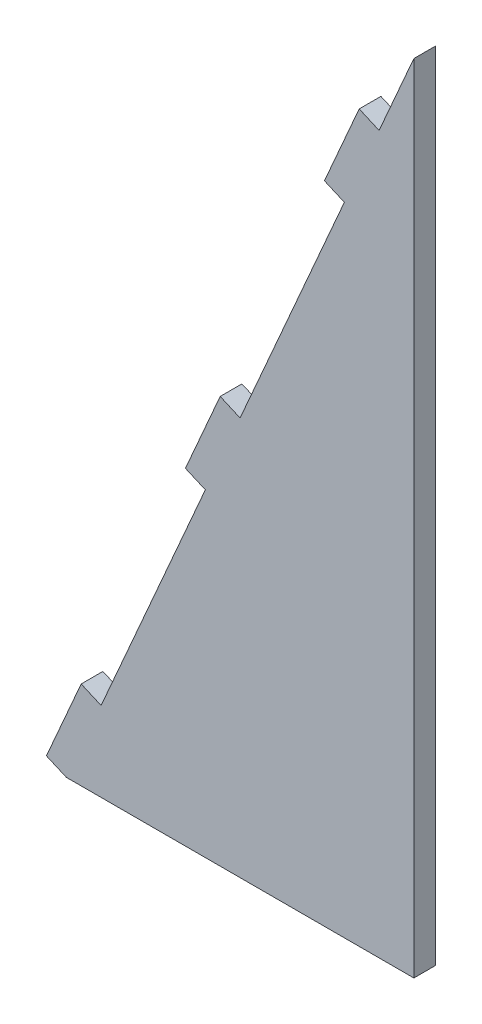
from build123d import *

# Parameters (mm, degrees)
EXTRUDE1_DEPTH  = 3.175
SKETCH2_W       = 3.175
SKETCH2_H       = 12.7
EXTRUDE2_DEPTH  = 3.175
LPATTERN1_COUNT = 3
LPATTERN1_PITCH = 50.8


with BuildPart() as part:
    # Sketch1 → Extrude1 (new body)
    with BuildSketch(Plane.XY):
        Polygon((0, 0), (50.8, 0), (50.8, 116.397422652), align=None)
    extrude(amount=EXTRUDE1_DEPTH)

    # Sketch2 → Extrude2 (add)
    with BuildSketch(Plane(origin=(0, 0, 0), x_dir=(0, 0, 1), z_dir=(-0.916515139, 0.4, 0))):
        with Locations((1.5875, 6.35)):
            Rectangle(SKETCH2_W, SKETCH2_H)
    extrude2 = extrude(amount=EXTRUDE2_DEPTH)

    # LPattern1: Extrude2 ×3
    with Locations(*[Vector(0.4, 0.916515139, 0) * (i * LPATTERN1_PITCH) for i in range(1, LPATTERN1_COUNT)]):
        add(extrude2)


solid = part.part
